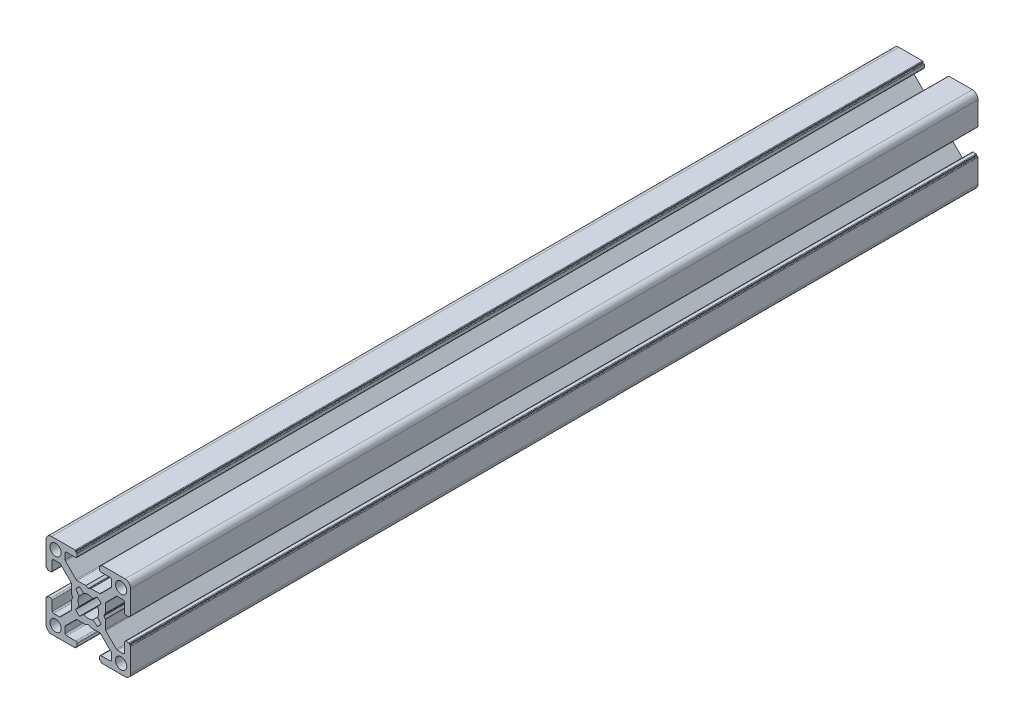
from build123d import *

# Parameters (mm, degrees)
CROQUIS1_R              = 2
SALIENTE_EXTRUIR1_DEPTH = 300


with BuildPart() as part:
    # Croquis1 → Saliente-Extruir1 (new body)
    with BuildSketch(Plane.XY.offset(1000)):
        with BuildLine():
            Line((9.800000436, -10.500000436), (10.100000436, -10.500000436))
            ThreePointArc((10.100000436, -10.500000436), (10.241421792, -10.441421792), (10.300000436, -10.300000436))
            Line((10.300000436, -10.300000436), (10.300000436, -2))
            ThreePointArc((10.300000436, -2), (9.714213998, -0.585786438), (8.300000436, 0))
            Line((8.300000436, 0), (0, 0))
            ThreePointArc((0, 0), (-0.141421356, -0.058578644), (-0.2, -0.2))
            Line((-0.2, -0.2), (-0.2, -0.5))
            Line((-0.2, -0.5), (-0.49999919, -0.5))
            ThreePointArc((-0.49999919, -0.5), (-0.641420811, -0.558578753), (-0.699999564, -0.700000374))
            Line((-0.699999564, -0.700000374), (-0.699999564, -1.700000763))
            ThreePointArc((-0.699999564, -1.700000763), (-0.553552955, -2.053554154), (-0.199999564, -2.200000763))
            Line((-0.199999564, -2.200000763), (3.050000763, -2.200000763))
            ThreePointArc((3.050000763, -2.200000763), (3.403554154, -2.346447372), (3.550000763, -2.700000763))
            Line((3.550000763, -2.700000763), (3.550000763, -4.743055509))
            ThreePointArc((3.550000763, -4.743055509), (3.511993279, -4.934269826), (3.403749103, -5.096413843))
            Line((3.403749103, -5.096413843), (-0.349053376, -8.853358334))
            ThreePointArc((-0.349053376, -8.853358334), (-0.511332616, -8.961886981), (-0.702801716, -9))
            Line((-0.702801716, -9), (-3.746809419, -9))
            ThreePointArc((-3.746809419, -9), (-3.798212795, -9.006718618), (-3.846162576, -9.026423071))
            Line((-3.846162576, -9.026423071), (-4.600646407, -9.458279719))
            ThreePointArc((-4.600646407, -9.458279719), (-4.699999564, -9.48470279), (-4.799352721, -9.458279719))
            Line((-4.799352721, -9.458279719), (-5.553836552, -9.026423071))
            ThreePointArc((-5.553836552, -9.026423071), (-5.601786333, -9.006718618), (-5.653189709, -9))
            Line((-5.653189709, -9), (-8.697197412, -9))
            ThreePointArc((-8.697197412, -9), (-8.888666513, -8.961886981), (-9.050945752, -8.853358334))
            Line((-9.050945752, -8.853358334), (-12.803748231, -5.096413843))
            ThreePointArc((-12.803748231, -5.096413843), (-12.911992407, -4.934269826), (-12.949999891, -4.743055509))
            Line((-12.949999891, -4.743055509), (-12.949999891, -2.700000763))
            ThreePointArc((-12.949999891, -2.700000763), (-12.803553282, -2.346447372), (-12.449999891, -2.200000763))
            Line((-12.449999891, -2.200000763), (-9.199999564, -2.200000763))
            ThreePointArc((-9.199999564, -2.200000763), (-8.846446173, -2.053554154), (-8.699999564, -1.700000763))
            Line((-8.699999564, -1.700000763), (-8.699999564, -0.700000374))
            ThreePointArc((-8.699999564, -0.700000374), (-8.758578317, -0.558578753), (-8.899999938, -0.5))
            Line((-8.899999938, -0.5), (-9.199999128, -0.5))
            Line((-9.199999128, -0.5), (-9.199999128, -0.2))
            ThreePointArc((-9.199999128, -0.2), (-9.258577772, -0.058578644), (-9.399999128, 0))
            Line((-9.399999128, 0), (-17.699999564, 0))
            ThreePointArc((-17.699999564, 0), (-19.114213126, -0.585786438), (-19.699999564, -2))
            Line((-19.699999564, -2), (-19.699999564, -10.300000436))
            ThreePointArc((-19.699999564, -10.300000436), (-19.64142092, -10.441421792), (-19.499999564, -10.500000436))
            Line((-19.499999564, -10.500000436), (-19.199999564, -10.500000436))
            Line((-19.199999564, -10.500000436), (-19.199999564, -10.799999627))
            ThreePointArc((-19.199999564, -10.799999627), (-19.141420811, -10.941421247), (-18.99999919, -11))
            Line((-18.99999919, -11), (-17.999998801, -11))
            ThreePointArc((-17.999998801, -11), (-17.64644541, -10.853553391), (-17.499998801, -10.5))
            Line((-17.499998801, -10.5), (-17.499998801, -7.249999673))
            ThreePointArc((-17.499998801, -7.249999673), (-17.353552192, -6.896446283), (-16.999998801, -6.749999673))
            Line((-16.999998801, -6.749999673), (-14.956944055, -6.749999673))
            ThreePointArc((-14.956944055, -6.749999673), (-14.765729738, -6.788007157), (-14.603585721, -6.896251334))
            Line((-14.603585721, -6.896251334), (-10.84664123, -10.649053813))
            ThreePointArc((-10.84664123, -10.649053813), (-10.738112583, -10.811333052), (-10.699999564, -11.002802152))
            Line((-10.699999564, -11.002802152), (-10.699999564, -14.046809855))
            ThreePointArc((-10.699999564, -14.046809855), (-10.693280947, -14.098213232), (-10.673576493, -14.146163012))
            Line((-10.673576493, -14.146163012), (-10.241719845, -14.900646843))
            ThreePointArc((-10.241719845, -14.900646843), (-10.215296774, -15), (-10.241719845, -15.099353157))
            Line((-10.241719845, -15.099353157), (-10.673576493, -15.853836988))
            ThreePointArc((-10.673576493, -15.853836988), (-10.693280947, -15.901786769), (-10.699999564, -15.953190146))
            Line((-10.699999564, -15.953190146), (-10.699999564, -18.997197848))
            ThreePointArc((-10.699999564, -18.997197848), (-10.738112583, -19.188666949), (-10.84664123, -19.350946188))
            Line((-10.84664123, -19.350946188), (-14.603585721, -23.103748667))
            ThreePointArc((-14.603585721, -23.103748667), (-14.765729738, -23.211992843), (-14.956944055, -23.250000327))
            Line((-14.956944055, -23.250000327), (-16.999998801, -23.250000327))
            ThreePointArc((-16.999998801, -23.250000327), (-17.353552192, -23.103553718), (-17.499998801, -22.750000327))
            Line((-17.499998801, -22.750000327), (-17.499998801, -19.5))
            ThreePointArc((-17.499998801, -19.5), (-17.64644541, -19.14644661), (-17.999998801, -19))
            Line((-17.999998801, -19), (-18.99999919, -19))
            ThreePointArc((-18.99999919, -19), (-19.141420811, -19.058578753), (-19.199999564, -19.200000374))
            Line((-19.199999564, -19.200000374), (-19.199999564, -19.499999564))
            Line((-19.199999564, -19.499999564), (-19.499999564, -19.499999564))
            ThreePointArc((-19.499999564, -19.499999564), (-19.64142092, -19.558578208), (-19.699999564, -19.699999564))
            Line((-19.699999564, -19.699999564), (-19.699999564, -28))
            ThreePointArc((-19.699999564, -28), (-19.114213126, -29.414213563), (-17.699999564, -30))
            Line((-17.699999564, -30), (-9.399999128, -30))
            ThreePointArc((-9.399999128, -30), (-9.258577772, -29.941421356), (-9.199999128, -29.8))
            Line((-9.199999128, -29.8), (-9.199999128, -29.5))
            Line((-9.199999128, -29.5), (-8.899999938, -29.5))
            ThreePointArc((-8.899999938, -29.5), (-8.758578317, -29.441421247), (-8.699999564, -29.299999627))
            Line((-8.699999564, -29.299999627), (-8.699999564, -28.299999237))
            ThreePointArc((-8.699999564, -28.299999237), (-8.846446173, -27.946445847), (-9.199999564, -27.799999237))
            Line((-9.199999564, -27.799999237), (-12.449999891, -27.799999237))
            ThreePointArc((-12.449999891, -27.799999237), (-12.803553282, -27.653552628), (-12.949999891, -27.299999237))
            Line((-12.949999891, -27.299999237), (-12.949999891, -25.256944491))
            ThreePointArc((-12.949999891, -25.256944491), (-12.911992407, -25.065730174), (-12.803748231, -24.903586157))
            Line((-12.803748231, -24.903586157), (-9.050945752, -21.146641666))
            ThreePointArc((-9.050945752, -21.146641666), (-8.888666513, -21.038113019), (-8.697197412, -21))
            Line((-8.697197412, -21), (-5.653189709, -21))
            ThreePointArc((-5.653189709, -21), (-5.601786333, -20.993281383), (-5.553836552, -20.973576929))
            Line((-5.553836552, -20.973576929), (-4.799352721, -20.541720281))
            ThreePointArc((-4.799352721, -20.541720281), (-4.699999564, -20.51529721), (-4.600646407, -20.541720281))
            Line((-4.600646407, -20.541720281), (-3.846162576, -20.973576929))
            ThreePointArc((-3.846162576, -20.973576929), (-3.798212795, -20.993281383), (-3.746809419, -21))
            Line((-3.746809419, -21), (-0.702801716, -21))
            ThreePointArc((-0.702801716, -21), (-0.511332616, -21.038113019), (-0.349053377, -21.146641666))
            Line((-0.349053377, -21.146641666), (3.403749103, -24.903586157))
            ThreePointArc((3.403749103, -24.903586157), (3.511993279, -25.065730174), (3.550000763, -25.256944491))
            Line((3.550000763, -25.256944491), (3.550000763, -27.299999237))
            ThreePointArc((3.550000763, -27.299999237), (3.403554154, -27.653552628), (3.050000763, -27.799999237))
            Line((3.050000763, -27.799999237), (-0.199999564, -27.799999237))
            ThreePointArc((-0.199999564, -27.799999237), (-0.553552955, -27.946445847), (-0.699999564, -28.299999237))
            Line((-0.699999564, -28.299999237), (-0.699999564, -29.299999627))
            ThreePointArc((-0.699999564, -29.299999627), (-0.641420811, -29.441421247), (-0.49999919, -29.5))
            Line((-0.49999919, -29.5), (-0.2, -29.5))
            Line((-0.2, -29.5), (-0.2, -29.8))
            ThreePointArc((-0.2, -29.8), (-0.141421356, -29.941421356), (0, -30))
            Line((0, -30), (8.300000436, -30))
            ThreePointArc((8.300000436, -30), (9.714213998, -29.414213563), (10.300000436, -28))
            Line((10.300000436, -28), (10.300000436, -19.699999564))
            ThreePointArc((10.300000436, -19.699999564), (10.241421792, -19.558578208), (10.100000436, -19.499999564))
            Line((10.100000436, -19.499999564), (9.800000436, -19.499999564))
            Line((9.800000436, -19.499999564), (9.800000436, -19.200000374))
            ThreePointArc((9.800000436, -19.200000374), (9.741421683, -19.058578753), (9.600000062, -19))
            Line((9.600000062, -19), (8.599999673, -19))
            ThreePointArc((8.599999673, -19), (8.246446283, -19.14644661), (8.099999673, -19.5))
            Line((8.099999673, -19.5), (8.099999673, -22.750000327))
            ThreePointArc((8.099999673, -22.750000327), (7.953553064, -23.103553718), (7.599999673, -23.250000327))
            Line((7.599999673, -23.250000327), (5.556944927, -23.250000327))
            ThreePointArc((5.556944927, -23.250000327), (5.36573061, -23.211992843), (5.203586593, -23.103748667))
            Line((5.203586593, -23.103748667), (1.446642102, -19.350946188))
            ThreePointArc((1.446642102, -19.350946188), (1.338113455, -19.188666949), (1.300000436, -18.997197848))
            Line((1.300000436, -18.997197848), (1.300000436, -15.953190145))
            ThreePointArc((1.300000436, -15.953190145), (1.293281819, -15.901786769), (1.273577365, -15.853836988))
            Line((1.273577365, -15.853836988), (0.841720717, -15.099353157))
            ThreePointArc((0.841720717, -15.099353157), (0.815297646, -15), (0.841720717, -14.900646843))
            Line((0.841720717, -14.900646843), (1.273577365, -14.146163012))
            ThreePointArc((1.273577365, -14.146163012), (1.293281819, -14.098213231), (1.300000436, -14.046809855))
            Line((1.300000436, -14.046809855), (1.300000436, -11.002802152))
            ThreePointArc((1.300000436, -11.002802152), (1.338113455, -10.811333052), (1.446642102, -10.649053813))
            Line((1.446642102, -10.649053813), (5.203586593, -6.896251334))
            ThreePointArc((5.203586593, -6.896251334), (5.36573061, -6.788007157), (5.556944927, -6.749999673))
            Line((5.556944927, -6.749999673), (7.599999673, -6.749999673))
            ThreePointArc((7.599999673, -6.749999673), (7.953553064, -6.896446283), (8.099999673, -7.249999673))
            Line((8.099999673, -7.249999673), (8.099999673, -10.5))
            ThreePointArc((8.099999673, -10.5), (8.246446283, -10.853553391), (8.599999673, -11))
            Line((8.599999673, -11), (9.600000062, -11))
            ThreePointArc((9.600000062, -11), (9.741421683, -10.941421247), (9.800000436, -10.799999627))
            Line((9.800000436, -10.799999627), (9.800000436, -10.500000436))
        make_face()
        with Locations((-16.300000272, -3.399999983)):
            Circle(CROQUIS1_R, mode=Mode.SUBTRACT)
        with Locations((6.900001145, -3.399999983)):
            Circle(CROQUIS1_R, mode=Mode.SUBTRACT)
        with Locations((-16.300000272, -26.600000017)):
            Circle(CROQUIS1_R, mode=Mode.SUBTRACT)
        with Locations((6.900001145, -26.600000017)):
            Circle(CROQUIS1_R, mode=Mode.SUBTRACT)
        with BuildLine():
            Line((-7.835928976, -10.481599097), (-6.300129088, -11.719438233))
            ThreePointArc((-6.300129088, -11.719438233), (-4.699999564, -11.35), (-3.09987004, -11.719438233))
            Line((-3.09987004, -11.719438233), (-1.564070152, -10.481599097))
            ThreePointArc((-1.564070152, -10.481599097), (-0.818997305, -11.10284444), (-0.194662672, -11.845330527))
            Line((-0.194662672, -11.845330527), (-1.419437832, -13.399870404))
            ThreePointArc((-1.419437832, -13.399870404), (-1.049999564, -15), (-1.419437832, -16.600129597))
            Line((-1.419437832, -16.600129597), (-0.194662672, -18.154669473))
            ThreePointArc((-0.194662672, -18.154669473), (-0.818997305, -18.897155561), (-1.564070152, -19.518400903))
            Line((-1.564070152, -19.518400903), (-3.09987004, -18.280561767))
            ThreePointArc((-3.09987004, -18.280561767), (-4.699999564, -18.65), (-6.300129088, -18.280561767))
            Line((-6.300129088, -18.280561767), (-7.835928976, -19.518400903))
            ThreePointArc((-7.835928976, -19.518400903), (-8.581001823, -18.897155561), (-9.205336456, -18.154669473))
            Line((-9.205336456, -18.154669473), (-7.980561295, -16.600129597))
            ThreePointArc((-7.980561295, -16.600129597), (-8.349999564, -15), (-7.980561296, -13.399870404))
            Line((-7.980561296, -13.399870404), (-9.205336456, -11.845330527))
            ThreePointArc((-9.205336456, -11.845330527), (-8.581001823, -11.10284444), (-7.835928976, -10.481599097))
        make_face(mode=Mode.SUBTRACT)
    extrude(amount=-SALIENTE_EXTRUIR1_DEPTH)


solid = part.part
